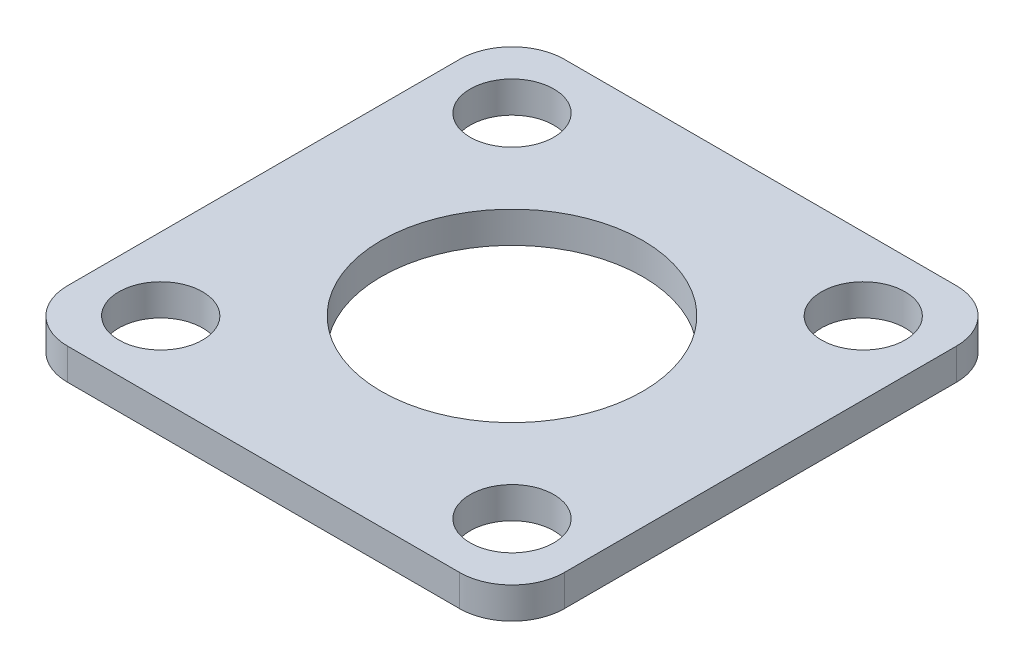
from build123d import *

# Parameters (mm, degrees)
SKETCH1_W           = 19
SKETCH1_H           = 19
SKETCH1_R           = 5
SKETCH1_R_2         = 1.6
BOSS_EXTRUDE1_DEPTH = 1.2
FILLET1_R           = 2


with BuildPart() as part:
    # Sketch1 → Boss-Extrude1 (new body)
    with BuildSketch(Plane(origin=(0, 0, 0), x_dir=(1, 0, 0), z_dir=(0, 1, 0))):
        Rectangle(SKETCH1_W, SKETCH1_H)
        Circle(SKETCH1_R, mode=Mode.SUBTRACT)
        with Locations((6.717514421, -6.717514421)):
            Circle(SKETCH1_R_2, mode=Mode.SUBTRACT)
        with Locations((-6.717514421, -6.717514421)):
            Circle(SKETCH1_R_2, mode=Mode.SUBTRACT)
        with Locations((-6.717514421, 6.717514421)):
            Circle(SKETCH1_R_2, mode=Mode.SUBTRACT)
        with Locations((6.717514421, 6.717514421)):
            Circle(SKETCH1_R_2, mode=Mode.SUBTRACT)
    extrude(amount=BOSS_EXTRUDE1_DEPTH)

    # Fillet1
    fillet1_edges = [part.edges().sort_by_distance(p)[0] for p in [
        (-9.5, 0.6, -9.5),
        (9.5, 0.6, -9.5),
        (9.5, 0.6, 9.5),
        (-9.5, 0.6, 9.5),
    ]]
    fillet(fillet1_edges, radius=FILLET1_R)


solid = part.part
